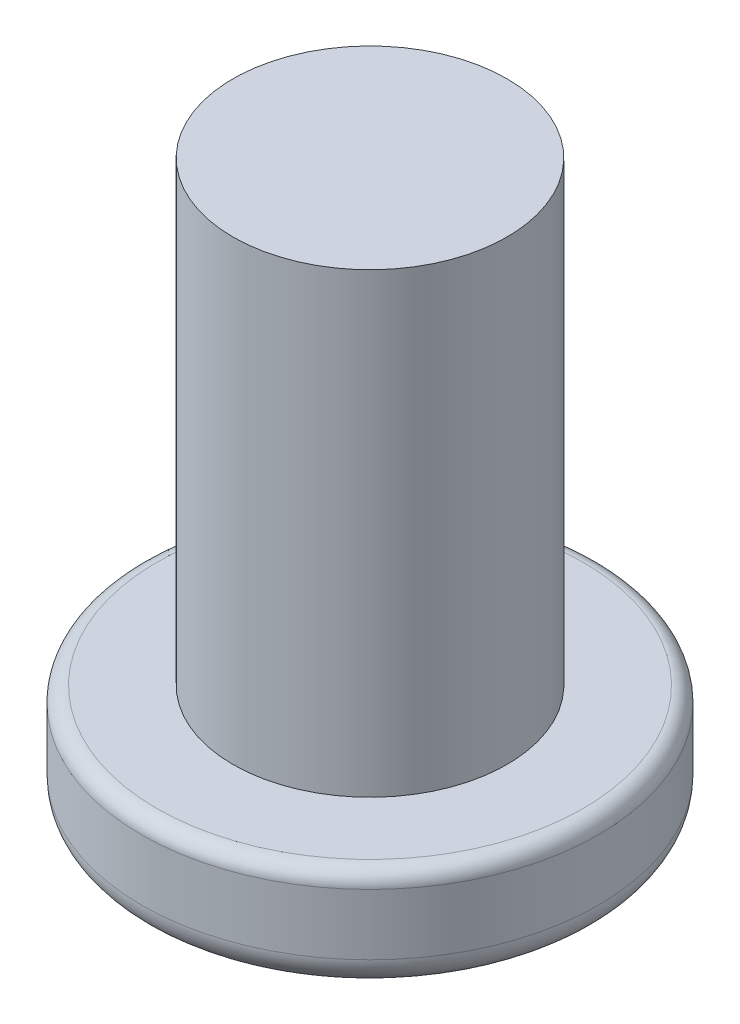
from build123d import *

# Parameters (mm, degrees)
SKETCH2_R           = 7.5
BOSS_EXTRUDE1_DEPTH = 3.5
SKETCH3_R           = 4.5
BOSS_EXTRUDE2_DEPTH = 15
FILLET1_R           = 1
FILLET2_R           = 0.5


with BuildPart() as part:
    # Sketch2 → Boss-Extrude1 (new body)
    with BuildSketch(Plane(origin=(0, 0, 0), x_dir=(1, 0, 0), z_dir=(0, 1, 0))):
        Circle(SKETCH2_R)
    extrude(amount=BOSS_EXTRUDE1_DEPTH)

    # Sketch3 → Boss-Extrude2 (add)
    with BuildSketch(Plane(origin=(0, 3.5, 0), x_dir=(1, 0, 0), z_dir=(0, 1, 0))):
        Circle(SKETCH3_R)
    extrude(amount=BOSS_EXTRUDE2_DEPTH)

    # Fillet1
    fillet1_edges = [part.edges().sort_by_distance(p)[0] for p in [
        (-7.5, 0, 0),
    ]]
    fillet(fillet1_edges, radius=FILLET1_R)

    # Fillet2
    fillet2_edges = [part.edges().sort_by_distance(p)[0] for p in [
        (-7.5, 3.5, 0),
    ]]
    fillet(fillet2_edges, radius=FILLET2_R)


solid = part.part
